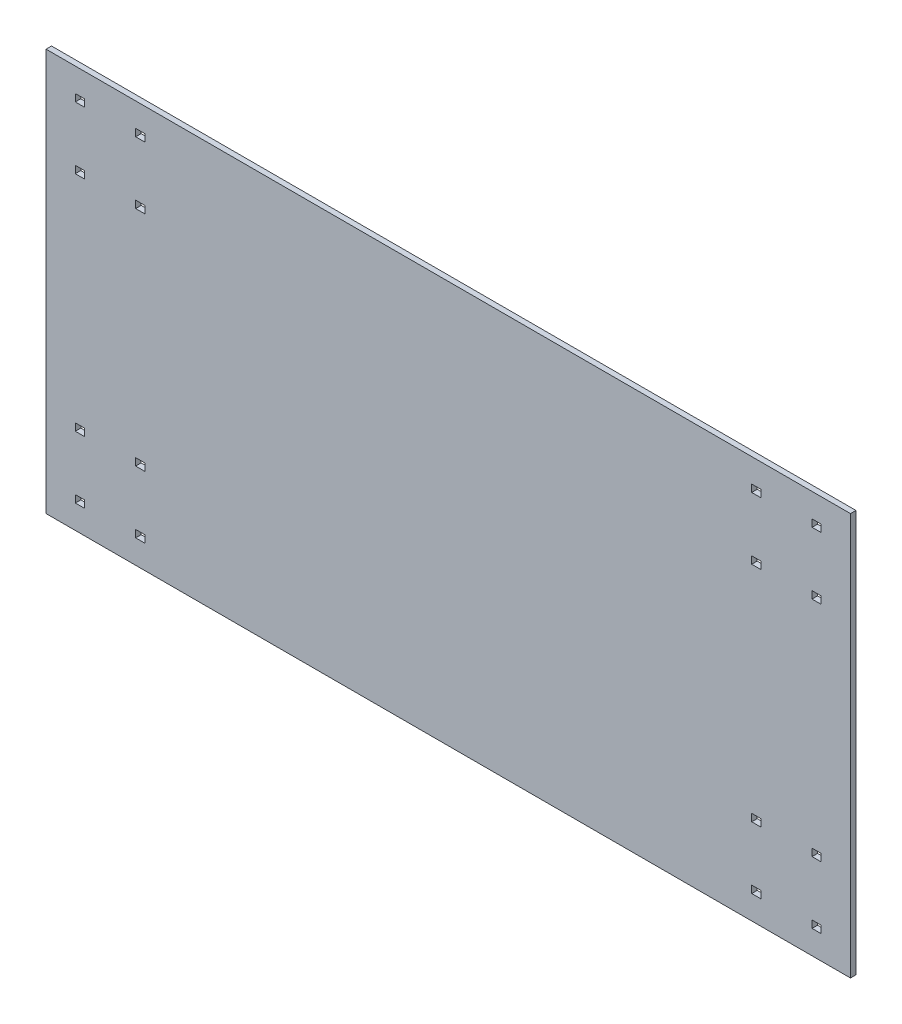
from build123d import *

# Parameters (mm, degrees)
ESQUISSE1_W             = 440
ESQUISSE1_H             = 220
BOSS_EXTRU_1_DEPTH      = 3
ESQUISSE2_W             = 5
ESQUISSE2_H             = 4
ENL_V_MAT_EXTRU_1_DEPTH = 3


with BuildPart() as part:
    # Esquisse1 → Boss.-Extru.1 (new body)
    with BuildSketch(Plane.XY):
        Rectangle(ESQUISSE1_W, ESQUISSE1_H)
    extrude(amount=BOSS_EXTRU_1_DEPTH)

    # Esquisse2 → Enlèv. mat.-Extru.1 (cut)
    with BuildSketch(Plane(origin=(0, 0, 0), x_dir=(-1, 0, 0), z_dir=(0, 0, -1))):
        with Locations((-201.5, 95)):
            Rectangle(ESQUISSE2_W, ESQUISSE2_H)
        with Locations((-168.5, 95)):
            Rectangle(ESQUISSE2_W, ESQUISSE2_H)
        with Locations((-168.5, 61)):
            Rectangle(ESQUISSE2_W, ESQUISSE2_H)
        with Locations((-201.5, 61)):
            Rectangle(ESQUISSE2_W, ESQUISSE2_H)
        with Locations((168.5, 61)):
            Rectangle(ESQUISSE2_W, ESQUISSE2_H)
        with Locations((201.5, 61)):
            Rectangle(ESQUISSE2_W, ESQUISSE2_H)
        with Locations((168.5, 95)):
            Rectangle(ESQUISSE2_W, ESQUISSE2_H)
        with Locations((201.5, 95)):
            Rectangle(ESQUISSE2_W, ESQUISSE2_H)
        with Locations((-168.5, -95)):
            Rectangle(ESQUISSE2_W, ESQUISSE2_H)
        with Locations((-201.5, -95)):
            Rectangle(ESQUISSE2_W, ESQUISSE2_H)
        with Locations((168.5, -61)):
            Rectangle(ESQUISSE2_W, ESQUISSE2_H)
        with Locations((201.5, -61)):
            Rectangle(ESQUISSE2_W, ESQUISSE2_H)
        with Locations((201.5, -95)):
            Rectangle(ESQUISSE2_W, ESQUISSE2_H)
        with Locations((168.5, -95)):
            Rectangle(ESQUISSE2_W, ESQUISSE2_H)
        with Locations((-168.5, -61)):
            Rectangle(ESQUISSE2_W, ESQUISSE2_H)
        with Locations((-201.5, -61)):
            Rectangle(ESQUISSE2_W, ESQUISSE2_H)
    extrude(amount=-ENL_V_MAT_EXTRU_1_DEPTH, mode=Mode.SUBTRACT)


solid = part.part
